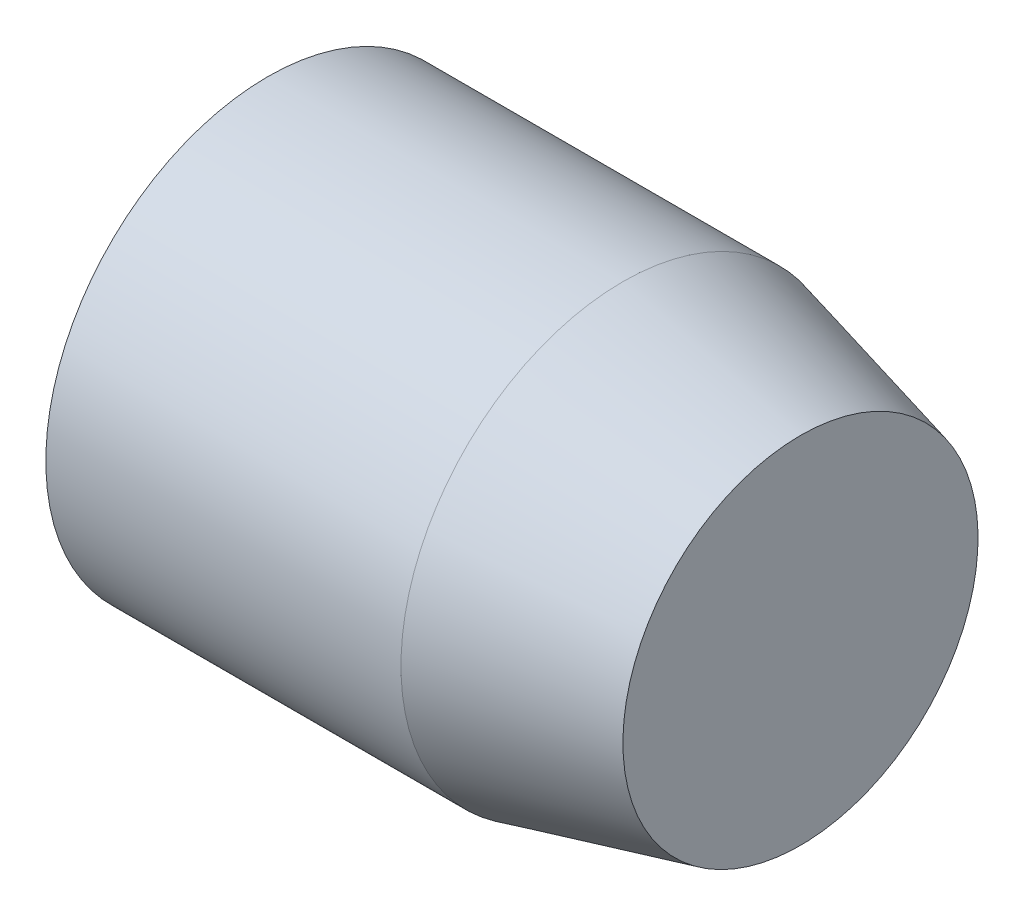
from build123d import *


with BuildPart() as part:
    # Sketch1 → Revolve1 (revolve)
    with BuildSketch(Plane.XY):
        Polygon((0, 0), (0, 5), (8, 5), (12, 4), (12, 0), align=None)
    revolve(axis=Axis((12, 0, 0), (-1, 0, 0)))


solid = part.part
